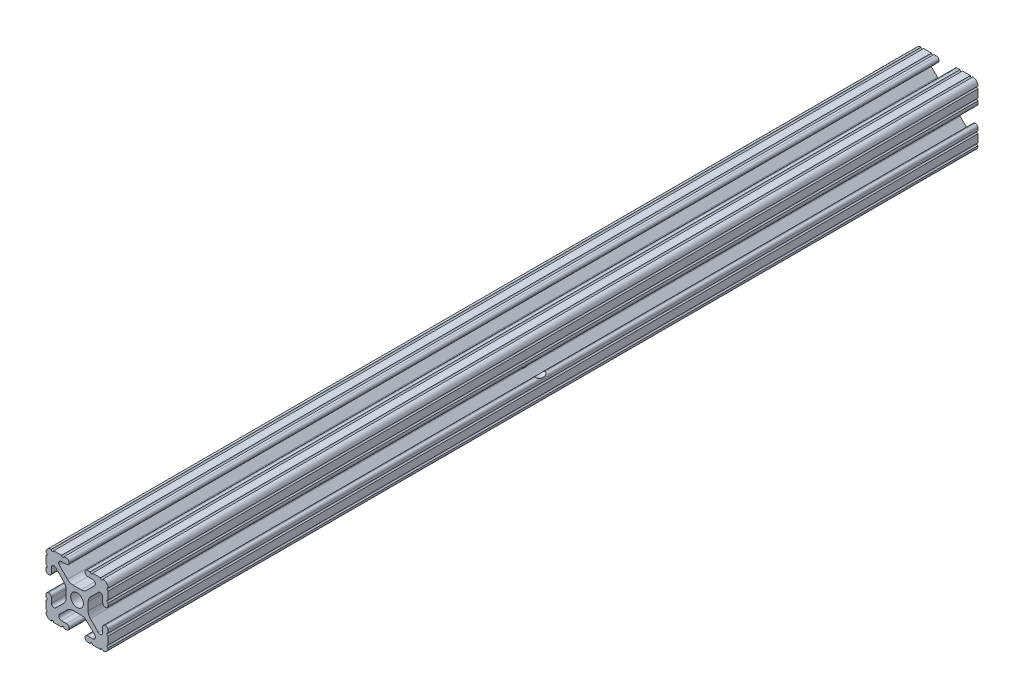
from build123d import *

# Parameters (mm, degrees)
SKETCH1_R           = 2.6035
BOSS_EXTRUDE1_DEPTH = 177.8
SKETCH2_R           = 3.81
CUT_EXTRUDE1_DEPTH  = 25.4


with BuildPart() as part:
    # Sketch1 → Boss-Extrude1 (new body, symmetric)
    with BuildSketch(Plane.XY):
        with BuildLine():
            Line((-7.179650497, -8.645192506), (-3.952270251, -5.423690499))
            ThreePointArc((-3.952270251, -5.423690499), (-2.922936451, -4.736929036), (-1.709253557, -4.4958))
            Line((-1.709253557, -4.4958), (1.709253557, -4.4958))
            ThreePointArc((1.709253557, -4.4958), (2.922936451, -4.736929036), (3.952270251, -5.423690499))
            Line((3.952270251, -5.423690499), (7.179650497, -8.645192506))
            ThreePointArc((7.179650497, -8.645192506), (7.41473083, -9.822813117), (6.416408329, -10.4902))
            Line((6.416408329, -10.4902), (4.287512407, -10.4902))
            ThreePointArc((4.287512407, -10.4902), (3.54574862, -10.79744862), (3.2385, -11.539212407))
            Line((3.2385, -11.539212407), (3.2385, -11.650987593))
            ThreePointArc((3.2385, -11.650987593), (3.54574862, -12.39275138), (4.287512407, -12.7))
            Line((4.287512407, -12.7), (5.317126718, -12.7))
            ThreePointArc((5.317126718, -12.7), (5.825126718, -12.192), (6.333126718, -12.7))
            Line((6.333126718, -12.7), (9.550443118, -12.7))
            ThreePointArc((9.550443118, -12.7), (10.058366869, -12.192000006), (10.566443095, -12.699847501))
            ThreePointArc((10.566443095, -12.699847501), (12.082537762, -12.08250727), (12.699846982, -10.566399977))
            ThreePointArc((12.699846982, -10.566399977), (12.192000006, -10.058323491), (12.7, -9.5504))
            Line((12.7, -9.5504), (12.7, -6.3330836))
            ThreePointArc((12.7, -6.3330836), (12.192, -5.8250836), (12.7, -5.3170836))
            Line((12.7, -5.3170836), (12.7, -4.287469289))
            ThreePointArc((12.7, -4.287469289), (12.39275138, -3.545705502), (11.650987593, -3.238456882))
            Line((11.650987593, -3.238456882), (11.539212407, -3.238456882))
            ThreePointArc((11.539212407, -3.238456882), (10.79744862, -3.545705502), (10.4902, -4.287469289))
            Line((10.4902, -4.287469289), (10.4902, -6.402089023))
            ThreePointArc((10.4902, -6.402089023), (9.856505071, -7.351067942), (8.737131347, -7.129408934))
            Line((8.737131347, -7.129408934), (5.441005833, -3.840816462))
            ThreePointArc((5.441005833, -3.840816462), (4.750877967, -2.809883091), (4.5085, -1.593185507))
            Line((4.5085, -1.593185507), (4.5085, 1.593185507))
            ThreePointArc((4.5085, 1.593185507), (4.750877967, 2.809883091), (5.441005833, 3.840816462))
            Line((5.441005833, 3.840816462), (8.737131347, 7.129408934))
            ThreePointArc((8.737131347, 7.129408934), (9.856505071, 7.351067942), (10.4902, 6.402089023))
            Line((10.4902, 6.402089023), (10.4902, 4.287469289))
            ThreePointArc((10.4902, 4.287469289), (10.79744862, 3.545705502), (11.539212407, 3.238456882))
            Line((11.539212407, 3.238456882), (11.650987593, 3.238456882))
            ThreePointArc((11.650987593, 3.238456882), (12.39275138, 3.545705502), (12.7, 4.287469289))
            Line((12.7, 4.287469289), (12.7, 5.3170836))
            ThreePointArc((12.7, 5.3170836), (12.192, 5.8250836), (12.7, 6.3330836))
            Line((12.7, 6.3330836), (12.7, 9.5504))
            ThreePointArc((12.7, 9.5504), (12.192000006, 10.058323491), (12.699846982, 10.566399977))
            ThreePointArc((12.699846982, 10.566399977), (12.082537762, 12.08250727), (10.566443095, 12.699847501))
            ThreePointArc((10.566443095, 12.699847501), (10.058366869, 12.192000006), (9.550443118, 12.7))
            Line((9.550443118, 12.7), (6.333126718, 12.7))
            ThreePointArc((6.333126718, 12.7), (5.825126718, 12.192), (5.317126718, 12.7))
            Line((5.317126718, 12.7), (4.287512407, 12.7))
            ThreePointArc((4.287512407, 12.7), (3.54574862, 12.39275138), (3.2385, 11.650987593))
            Line((3.2385, 11.650987593), (3.2385, 11.539212407))
            ThreePointArc((3.2385, 11.539212407), (3.54574862, 10.79744862), (4.287512407, 10.4902))
            Line((4.287512407, 10.4902), (6.476788598, 10.4902))
            ThreePointArc((6.476788598, 10.4902), (7.432222385, 9.85140422), (7.207036008, 8.724370562))
            Line((7.207036008, 8.724370562), (3.898272566, 5.423169045))
            ThreePointArc((3.898272566, 5.423169045), (2.869120213, 4.736787962), (1.655778399, 4.4958))
            Line((1.655778399, 4.4958), (-1.655778399, 4.4958))
            ThreePointArc((-1.655778399, 4.4958), (-2.869120213, 4.736787962), (-3.898272566, 5.423169045))
            Line((-3.898272566, 5.423169045), (-7.207036008, 8.724370562))
            ThreePointArc((-7.207036008, 8.724370562), (-7.432222385, 9.85140422), (-6.476788598, 10.4902))
            Line((-6.476788598, 10.4902), (-4.287512407, 10.4902))
            ThreePointArc((-4.287512407, 10.4902), (-3.54574862, 10.79744862), (-3.2385, 11.539212407))
            Line((-3.2385, 11.539212407), (-3.2385, 11.650987593))
            ThreePointArc((-3.2385, 11.650987593), (-3.54574862, 12.39275138), (-4.287512407, 12.7))
            Line((-4.287512407, 12.7), (-5.317126718, 12.7))
            ThreePointArc((-5.317126718, 12.7), (-5.825126718, 12.192), (-6.333126718, 12.7))
            Line((-6.333126718, 12.7), (-9.550443118, 12.7))
            ThreePointArc((-9.550443118, 12.7), (-10.058366869, 12.192000006), (-10.566443095, 12.699847501))
            ThreePointArc((-10.566443095, 12.699847501), (-12.082537762, 12.08250727), (-12.699846982, 10.566399977))
            ThreePointArc((-12.699846982, 10.566399977), (-12.192000006, 10.058323491), (-12.7, 9.5504))
            Line((-12.7, 9.5504), (-12.7, 6.3330836))
            ThreePointArc((-12.7, 6.3330836), (-12.192, 5.8250836), (-12.7, 5.3170836))
            Line((-12.7, 5.3170836), (-12.7, 4.287469289))
            ThreePointArc((-12.7, 4.287469289), (-12.39275138, 3.545705502), (-11.650987593, 3.238456882))
            Line((-11.650987593, 3.238456882), (-11.539212407, 3.238456882))
            ThreePointArc((-11.539212407, 3.238456882), (-10.79744862, 3.545705502), (-10.4902, 4.287469289))
            Line((-10.4902, 4.287469289), (-10.4902, 6.402089023))
            ThreePointArc((-10.4902, 6.402089023), (-9.856505071, 7.351067942), (-8.737131347, 7.129408934))
            Line((-8.737131347, 7.129408934), (-5.441005833, 3.840816462))
            ThreePointArc((-5.441005833, 3.840816462), (-4.750877967, 2.809883091), (-4.5085, 1.593185507))
            Line((-4.5085, 1.593185507), (-4.5085, -1.593185507))
            ThreePointArc((-4.5085, -1.593185507), (-4.750877967, -2.809883091), (-5.441005833, -3.840816462))
            Line((-5.441005833, -3.840816462), (-8.737131347, -7.129408934))
            ThreePointArc((-8.737131347, -7.129408934), (-9.856505071, -7.351067942), (-10.4902, -6.402089023))
            Line((-10.4902, -6.402089023), (-10.4902, -4.287469289))
            ThreePointArc((-10.4902, -4.287469289), (-10.79744862, -3.545705502), (-11.539212407, -3.238456882))
            Line((-11.539212407, -3.238456882), (-11.650987593, -3.238456882))
            ThreePointArc((-11.650987593, -3.238456882), (-12.39275138, -3.545705502), (-12.7, -4.287469289))
            Line((-12.7, -4.287469289), (-12.7, -5.3170836))
            ThreePointArc((-12.7, -5.3170836), (-12.192, -5.8250836), (-12.7, -6.3330836))
            Line((-12.7, -6.3330836), (-12.7, -9.5504))
            ThreePointArc((-12.7, -9.5504), (-12.192000006, -10.058323491), (-12.699846982, -10.566399977))
            ThreePointArc((-12.699846982, -10.566399977), (-12.082537762, -12.08250727), (-10.566443095, -12.699847501))
            ThreePointArc((-10.566443095, -12.699847501), (-10.058366869, -12.192000006), (-9.550443118, -12.7))
            Line((-9.550443118, -12.7), (-6.333126718, -12.7))
            ThreePointArc((-6.333126718, -12.7), (-5.825126718, -12.192), (-5.317126718, -12.7))
            Line((-5.317126718, -12.7), (-4.287512407, -12.7))
            ThreePointArc((-4.287512407, -12.7), (-3.54574862, -12.39275138), (-3.2385, -11.650987593))
            Line((-3.2385, -11.650987593), (-3.2385, -11.539212407))
            ThreePointArc((-3.2385, -11.539212407), (-3.54574862, -10.79744862), (-4.287512407, -10.4902))
            Line((-4.287512407, -10.4902), (-6.416408329, -10.4902))
            ThreePointArc((-6.416408329, -10.4902), (-7.41473083, -9.822813117), (-7.179650497, -8.645192506))
        make_face()
        Circle(SKETCH1_R, mode=Mode.SUBTRACT)
    extrude(amount=BOSS_EXTRUDE1_DEPTH, both=True)

    # Sketch2 → Cut-Extrude1 (cut)
    with BuildSketch(Plane.ZY.offset(12.7)):
        Circle(SKETCH2_R)
    extrude(amount=-CUT_EXTRUDE1_DEPTH, mode=Mode.SUBTRACT)


solid = part.part
